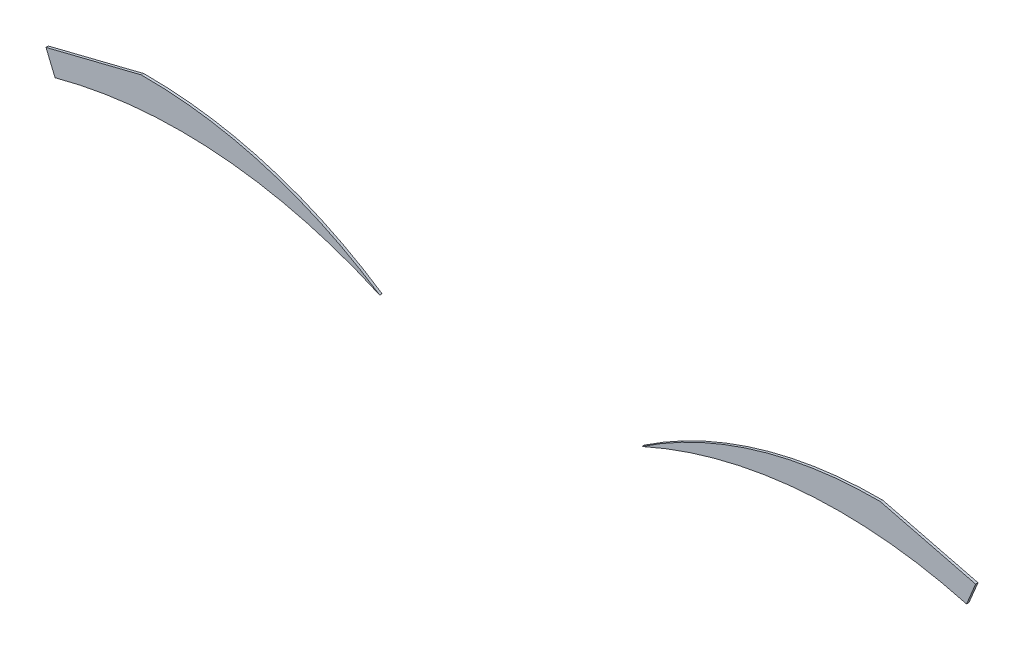
from build123d import *

# Parameters (mm, degrees)
SALIENTE_EXTRUIR1_DEPTH   = 0.1
SALIENTE_EXTRUIR1_2_DEPTH = 0.1


with BuildPart() as part:
    # Model → Saliente-Extruir1 (new body)
    with BuildSketch(Plane.XY):
        with BuildLine():
            Line((30.879125436, 32.586549458), (30.498742543, 33.499779932))
            Line((30.498742543, 33.499779932), (34.498742543, 34.499779932))
            ThreePointArc((34.498742543, 34.499779932), (39.724293984, 33.751618068), (44.498742543, 31.499779932))
            ThreePointArc((44.498742543, 31.499779932), (37.783634438, 33.229970005), (30.879125436, 32.586549458))
        make_face()
    extrude(amount=SALIENTE_EXTRUIR1_DEPTH)


with BuildPart() as body_2:
    # Model → Saliente-Extruir1 2 (new body)
    with BuildSketch(Plane.XY):
        with BuildLine():
            Line((65.501257457, 34.499779932), (69.501257457, 33.499779932))
            Line((69.501257457, 33.499779932), (69.120874564, 32.586549458))
            ThreePointArc((69.120874564, 32.586549458), (62.216365562, 33.229970005), (55.501257457, 31.499779932))
            ThreePointArc((55.501257457, 31.499779932), (60.275706016, 33.751618068), (65.501257457, 34.499779932))
        make_face()
    extrude(amount=SALIENTE_EXTRUIR1_2_DEPTH)


solid = Compound([part.part, body_2.part])
